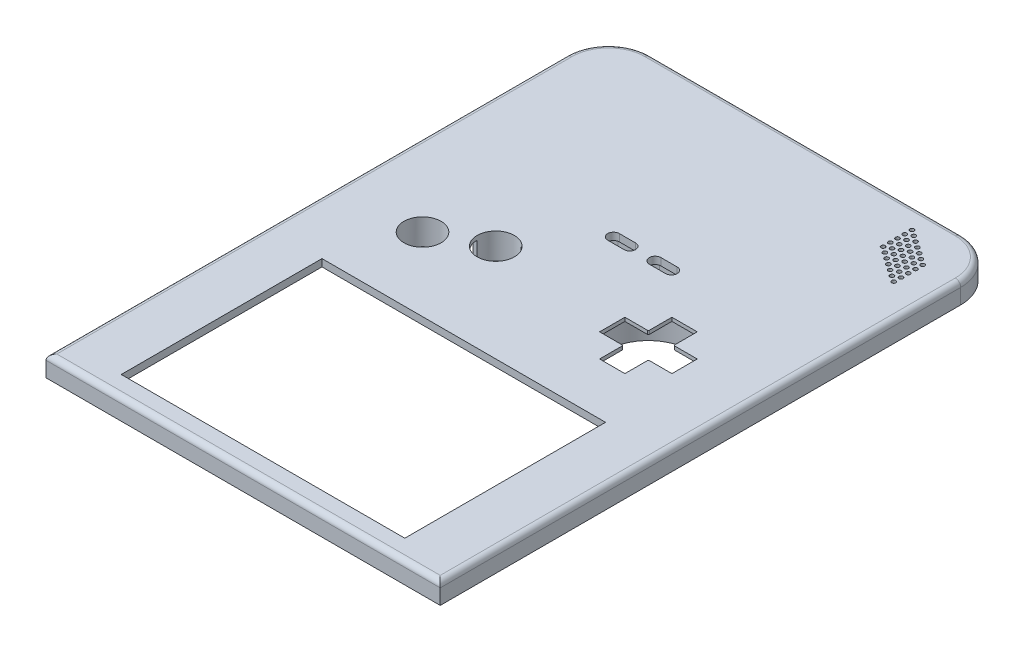
from build123d import *

# Parameters (mm, degrees)
SKETCH1_W            = 109
SKETCH1_H            = 155.5
BOSS_EXTRUDE1_DEPTH  = 5.7
SKETCH2_W            = 104.9
SKETCH2_H            = 151.4
CUT_EXTRUDE1_DEPTH   = 3.7
CUT_EXTRUDE3_DEPTH   = 6.7
SKETCH15_R           = 12.3
SKETCH15_R_2         = 11.3
BOSS_EXTRUDE27_DEPTH = 3.15
SKETCH4_W            = 78.4
SKETCH4_H            = 55.5
CUT_EXTRUDE4_DEPTH   = 6.7
SKETCH5_R            = 3.85
BOSS_EXTRUDE3_DEPTH  = 3.05
SKETCH8_R            = 12.85
SKETCH8_R_2          = 11.75
SKETCH8_R_3          = 6.25
SKETCH8_R_4          = 5.15
BOSS_EXTRUDE5_DEPTH  = 5.15
SKETCH9_R            = 1
BOSS_EXTRUDE6_DEPTH  = 5.6
CUT_EXTRUDE7_REACH   = 4
SKETCH12_R           = 11.75
CUT_EXTRUDE8_DEPTH   = 1
CUT_EXTRUDE9_REACH   = 4
SKETCH13_R           = 5.15
BOSS_EXTRUDE10_DEPTH = 5.7
SKETCH16_R           = 0.562045066
CUT_EXTRUDE13_DEPTH  = 2
FILLET3_R            = 0.25
CUT_EXTRUDE24_DEPTH  = 6
SKETCH19_R           = 1
BOSS_EXTRUDE28_DEPTH = 5.6
CHAMFER1_SIZE        = 0.25
CUT_EXTRUDE18_DEPTH  = 8.6
BOSS_EXTRUDE29_START = -5.7
BOSS_EXTRUDE29_DEPTH = 3.7
FILLET2_R            = 1.5
BOSS_EXTRUDE30_DEPTH = 3.15
CUT_EXTRUDE26_DEPTH  = 8.15


with BuildPart() as part:
    # Sketch1 → Boss-Extrude1 (new body)
    with BuildSketch(Plane(origin=(0, 0, 0), x_dir=(1, 0, 0), z_dir=(0, 1, 0))):
        Rectangle(SKETCH1_W, SKETCH1_H)
    extrude(amount=BOSS_EXTRUDE1_DEPTH)

    # Sketch2 → Cut-Extrude1 (cut)
    with BuildSketch(Plane(origin=(0, 0, 0), x_dir=(-1, 0, 0), z_dir=(0, -1, 0))):
        Rectangle(SKETCH2_W, SKETCH2_H)
    extrude(amount=-CUT_EXTRUDE1_DEPTH, mode=Mode.SUBTRACT)

    # Sketch3 → Cut-Extrude3 (cut, through all)
    with BuildSketch(Plane(origin=(0, 5.7, 0), x_dir=(1, 0, 0), z_dir=(0, 1, 0))):
        with BuildLine():
            ThreePointArc((42.9, 77.75), (51.102438662, 74.352438662), (54.5, 66.15))
            Line((54.5, 66.15), (54.5, 77.75))
            Line((54.5, 77.75), (42.9, 77.75))
        make_face()
    extrude(amount=-CUT_EXTRUDE3_DEPTH, mode=Mode.SUBTRACT)

    # Sketch15 → Boss-Extrude27 (add)
    with BuildSketch(Plane.XZ.offset(-3.7)):
        with Locations((41.14, -64.39)):
            Circle(SKETCH15_R)
        with Locations((41.14, -64.39)):
            Circle(SKETCH15_R_2, mode=Mode.SUBTRACT)
    extrude(amount=BOSS_EXTRUDE27_DEPTH)

    # Sketch4 → Cut-Extrude4 (cut, through all)
    with BuildSketch(Plane(origin=(0, 5.7, 0), x_dir=(1, 0, 0), z_dir=(0, 1, 0))):
        with Locations((0, -44.5)):
            Rectangle(SKETCH4_W, SKETCH4_H)
    extrude(amount=-CUT_EXTRUDE4_DEPTH, mode=Mode.SUBTRACT)

    # Sketch5 → Boss-Extrude3 (add)
    with BuildSketch(Plane.XZ.offset(-3.7)):
        with Locations((46.05, 68.22282905)):
            Circle(SKETCH5_R)
        Polygon((49.177494429, 69.423361681), (46.574055458, 71.531584991), (43.446561029, 70.33105236), (42.922505571, 67.022296419), (45.525944542, 64.914073109), (48.653438971, 66.11460574), align=None, mode=Mode.SUBTRACT)
        with Locations((-46.05, 68.22282905)):
            Circle(SKETCH5_R)
        Polygon((-48.653438971, 66.11460574), (-49.177494429, 69.423361681), (-46.574055458, 71.531584991), (-43.446561029, 70.33105236), (-42.922505571, 67.022296419), (-45.525944542, 64.914073109), align=None, mode=Mode.SUBTRACT)
        with Locations((-46.05, -68.22282905)):
            Circle(SKETCH5_R)
        Polygon((-49.177494429, -69.423361681), (-46.574055458, -71.531584991), (-43.446561029, -70.33105236), (-42.922505571, -67.022296419), (-45.525944542, -64.914073109), (-48.653438971, -66.11460574), align=None, mode=Mode.SUBTRACT)
    extrude(amount=BOSS_EXTRUDE3_DEPTH)

    # Sketch8 → Boss-Extrude5 (add)
    with BuildSketch(Plane.XZ.offset(-3.7)):
        with Locations((26.715, -7.585)):
            Circle(SKETCH8_R)
        with Locations((26.715, -7.585)):
            Circle(SKETCH8_R_2, mode=Mode.SUBTRACT)
        with Locations((-31.65, -3.5)):
            Circle(SKETCH8_R_3)
        with Locations((-31.65, -3.5)):
            Circle(SKETCH8_R_4, mode=Mode.SUBTRACT)
        with Locations((-18.15, -10.25)):
            Circle(SKETCH8_R_3)
        with Locations((-18.15, -10.25)):
            Circle(SKETCH8_R_4, mode=Mode.SUBTRACT)
        with BuildLine():
            Line((0.4, -29.75), (-4.1, -29.75))
            ThreePointArc((-4.1, -29.75), (-5.1, -28.75), (-4.1, -27.75))
            Line((-4.1, -27.75), (0.4, -27.75))
            ThreePointArc((0.4, -27.75), (1.4, -28.75), (0.4, -29.75))
        make_face()
        with BuildLine():
            Line((11.9, -29.75), (7.4, -29.75))
            ThreePointArc((7.4, -29.75), (6.4, -28.75), (7.4, -27.75))
            Line((7.4, -27.75), (11.9, -27.75))
            ThreePointArc((11.9, -27.75), (12.9, -28.75), (11.9, -29.75))
        make_face()
    extrude(amount=BOSS_EXTRUDE5_DEPTH)

    # Sketch9 → Boss-Extrude6 (add)
    with BuildSketch(Plane.XZ.offset(-3.7)):
        with Locations((16.108398282, 3.021601718)):
            Circle(SKETCH9_R)
        with Locations((37.321601718, -18.191601718)):
            Circle(SKETCH9_R)
    extrude(amount=BOSS_EXTRUDE6_DEPTH)

    # Sketch11 → Cut-Extrude7 (cut, up to next)
    with BuildSketch(Plane.XZ.offset(-3.7), mode=Mode.PRIVATE) as cut_extrude7_sk1:
        Polygon((30.215, -4.085), (30.215, 2.415), (23.215, 2.415), (23.215, -4.085), (16.715, -4.085), (16.715, -11.085), (23.215, -11.085), (23.215, -17.585), (30.215, -17.585), (30.215, -11.085), (36.715, -11.085), (36.715, -4.085), align=None)
    cut_extrude7_tool1 = extrude(cut_extrude7_sk1.sketch, amount=-CUT_EXTRUDE7_REACH, mode=Mode.PRIVATE) & part.part
    add(cut_extrude7_tool1.solids().sort_by_distance((26.715, 3.7, -7.585))[0], mode=Mode.SUBTRACT)

    # Sketch12 → Cut-Extrude8 (cut)
    with BuildSketch(Plane.XZ.offset(-3.7)):
        with Locations((26.715, -7.585)):
            Circle(SKETCH12_R)
    extrude(amount=-CUT_EXTRUDE8_DEPTH, mode=Mode.SUBTRACT)

    # Sketch13 → Cut-Extrude9 (cut, up to next)
    with BuildSketch(Plane(origin=(0, 3.7, 0), x_dir=(-1, 0, 0), z_dir=(0, -1, 0)), mode=Mode.PRIVATE) as cut_extrude9_sk1:
        with Locations((31.65, 3.5)):
            Circle(SKETCH13_R)
    cut_extrude9_tool1 = extrude(cut_extrude9_sk1.sketch, amount=-CUT_EXTRUDE9_REACH, mode=Mode.PRIVATE) & part.part
    add(cut_extrude9_tool1.solids().sort_by_distance((-31.65, 3.7, -3.5))[0], mode=Mode.SUBTRACT)
    # Sketch13 → Cut-Extrude9 (cut, up to next)
    with BuildSketch(Plane(origin=(0, 3.7, 0), x_dir=(-1, 0, 0), z_dir=(0, -1, 0)), mode=Mode.PRIVATE) as cut_extrude9_sk2:
        with Locations((18.15, 10.25)):
            Circle(SKETCH13_R)
    cut_extrude9_tool2 = extrude(cut_extrude9_sk2.sketch, amount=-CUT_EXTRUDE9_REACH, mode=Mode.PRIVATE) & part.part
    add(cut_extrude9_tool2.solids().sort_by_distance((-18.15, 3.7, -10.25))[0], mode=Mode.SUBTRACT)

    # Sketch3_9 → Boss-Extrude10 (add)
    with BuildSketch(Plane(origin=(0, 5.7, 0), x_dir=(1, 0, 0), z_dir=(0, 1, 0))):
        with BuildLine():
            ThreePointArc((42.9, 75.7), (49.65286976, 72.90286976), (52.45, 66.15))
            Line((52.45, 66.15), (54.5, 66.15))
            ThreePointArc((54.5, 66.15), (51.102438662, 74.352438662), (42.9, 77.75))
            Line((42.9, 77.75), (42.9, 75.7))
        make_face()
    extrude(amount=-BOSS_EXTRUDE10_DEPTH)

    # Sketch16 → Cut-Extrude13 (cut)
    with BuildSketch(Plane(origin=(0, 3.7, 0), x_dir=(-1, 0, 0), z_dir=(0, -1, 0))):
        with Locations((-35.52735827, 63.649490355)):
            Circle(SKETCH16_R)
        with Locations((-37.165662359, 62.502337482)):
            Circle(SKETCH16_R)
        with Locations((-38.803966447, 61.35518461)):
            Circle(SKETCH16_R)
        with Locations((-40.442270536, 60.208031737)):
            Circle(SKETCH16_R)
        with Locations((-42.080574624, 59.060878864)):
            Circle(SKETCH16_R)
        with Locations((-43.718878713, 57.913725991)):
            Circle(SKETCH16_R)
        with Locations((-45.357182802, 56.766573119)):
            Circle(SKETCH16_R)
        with Locations((-37.165662359, 64.502337482)):
            Circle(SKETCH16_R)
        with Locations((-38.803966447, 63.35518461)):
            Circle(SKETCH16_R)
        with Locations((-40.442270536, 62.208031737)):
            Circle(SKETCH16_R)
        with Locations((-42.080574624, 61.060878864)):
            Circle(SKETCH16_R)
        with Locations((-43.718878713, 59.913725991)):
            Circle(SKETCH16_R)
        with Locations((-45.357182802, 58.766573119)):
            Circle(SKETCH16_R)
        with Locations((-37.165662359, 66.502337482)):
            Circle(SKETCH16_R)
        with Locations((-38.803966447, 65.35518461)):
            Circle(SKETCH16_R)
        with Locations((-40.442270536, 64.208031737)):
            Circle(SKETCH16_R)
        with Locations((-42.080574624, 63.060878864)):
            Circle(SKETCH16_R)
        with Locations((-43.718878713, 61.913725991)):
            Circle(SKETCH16_R)
        with Locations((-45.357182802, 60.766573119)):
            Circle(SKETCH16_R)
        with Locations((-37.165662359, 68.502337482)):
            Circle(SKETCH16_R)
        with Locations((-38.803966447, 67.35518461)):
            Circle(SKETCH16_R)
        with Locations((-40.442270536, 66.208031737)):
            Circle(SKETCH16_R)
        with Locations((-42.080574624, 65.060878864)):
            Circle(SKETCH16_R)
        with Locations((-43.718878713, 63.913725991)):
            Circle(SKETCH16_R)
        with Locations((-45.357182802, 62.766573119)):
            Circle(SKETCH16_R)
        with Locations((-37.165662359, 70.502337482)):
            Circle(SKETCH16_R)
        with Locations((-38.803966447, 69.35518461)):
            Circle(SKETCH16_R)
        with Locations((-40.442270536, 68.208031737)):
            Circle(SKETCH16_R)
        with Locations((-42.080574624, 67.060878864)):
            Circle(SKETCH16_R)
        with Locations((-43.718878713, 65.913725991)):
            Circle(SKETCH16_R)
        with Locations((-45.357182802, 64.766573119)):
            Circle(SKETCH16_R)
        with Locations((-35.52735827, 65.649490355)):
            Circle(SKETCH16_R)
        with Locations((-35.52735827, 67.649490355)):
            Circle(SKETCH16_R)
        with Locations((-35.52735827, 69.649490355)):
            Circle(SKETCH16_R)
        with Locations((-35.52735827, 71.649490355)):
            Circle(SKETCH16_R)
    extrude(amount=-CUT_EXTRUDE13_DEPTH, mode=Mode.SUBTRACT)

    # Fillet3
    fillet3_edges = [part.edges().sort_by_distance(p)[0] for p in [
        (30.215, 5.2, -11.085),
        (23.215, 5.2, -11.085),
        (23.215, 5.2, -4.085),
        (30.215, 5.2, -4.085),
    ]]
    fillet(fillet3_edges, radius=FILLET3_R)

    # Sketch18 → Cut-Extrude24 (cut)
    with BuildSketch(Plane.XZ.offset(1.45)):
        Polygon((-16.137205771, -6.051171399), (-14.510860175, -7.677516996), (-10.832101403, -4.558447), (-12.458447, -2.932101403), align=None)
        with BuildLine():
            Line((-18.15, -10.25), (-21.536530628, -3.165016871))
            ThreePointArc((-21.536530628, -3.165016871), (-24.793008767, -6.062398043), (-26.002743191, -10.25))
            Line((-26.002743191, -10.25), (-18.15, -10.25))
        make_face()
        Polygon((-12.458447, -17.567898597), (-10.832101403, -15.941553), (-14.510860175, -12.822483004), (-16.137205771, -14.448828601), align=None)
    extrude(amount=-CUT_EXTRUDE24_DEPTH, mode=Mode.SUBTRACT)

    # Sketch19 → Boss-Extrude28 (add)
    with BuildSketch(Plane.XZ.offset(-3.7)):
        with Locations((-30.260814579, -11.378462024)):
            Circle(SKETCH19_R)
    extrude(amount=BOSS_EXTRUDE28_DEPTH)

    # Chamfer1
    chamfer1_edges = [part.edges().sort_by_distance(p)[0] for p in [
        (15.108398282, -1.9, 3.021601718),
        (36.321601718, -1.9, -18.191601718),
        (-31.260814579, -1.9, -11.378462024),
    ]]
    chamfer(chamfer1_edges, length=CHAMFER1_SIZE)

    # Sketch3_12 → Cut-Extrude18 (cut, through all)
    with BuildSketch(Plane(origin=(0, 5.7, 0), x_dir=(1, 0, 0), z_dir=(0, 1, 0))):
        with BuildLine():
            ThreePointArc((-54.5, 66.15), (-51.102438662, 74.352438662), (-42.9, 77.75))
            Line((-42.9, 77.75), (-54.5, 77.75))
            Line((-54.5, 77.75), (-54.5, 66.15))
        make_face()
    extrude(amount=-CUT_EXTRUDE18_DEPTH, mode=Mode.SUBTRACT)

    # Sketch3_14 → Boss-Extrude29 (add)
    with BuildSketch(Plane(origin=(0, 5.7, 0), x_dir=(1, 0, 0), z_dir=(0, 1, 0)).offset(BOSS_EXTRUDE29_START)):
        with BuildLine():
            Line((-42.9, 75.7), (-42.9, 77.75))
            ThreePointArc((-42.9, 77.75), (-51.102438662, 74.352438662), (-54.5, 66.15))
            Line((-54.5, 66.15), (-52.45, 66.15))
            ThreePointArc((-52.45, 66.15), (-49.65286976, 72.90286976), (-42.9, 75.7))
        make_face()
    extrude(amount=BOSS_EXTRUDE29_DEPTH)

    # Fillet2
    fillet2_edges = [part.edges().sort_by_distance(p)[0] for p in [
        (0, 5.7, 77.75),
        (0, 5.7, -77.75),
        (51.102438662, 5.7, -74.352438662),
        (54.5, 5.7, 5.8),
        (-54.5, 5.7, 5.8),
        (-51.102438662, 5.7, -74.352438662),
    ]]
    fillet(fillet2_edges, radius=FILLET2_R)

    # Sketch22 → Boss-Extrude30 (add)
    with BuildSketch(Plane.XZ.offset(-3.7)):
        with BuildLine():
            Line((12.814788301, -32), (-5.185211699, -32))
            ThreePointArc((-5.185211699, -32), (-8.185211699, -29), (-5.185211699, -26))
            Line((-5.185211699, -26), (12.814788301, -26))
            ThreePointArc((12.814788301, -26), (15.814788301, -29), (12.814788301, -32))
        make_face()
        with BuildLine():
            Line((6.4, -27), (12.9, -27))
            ThreePointArc((12.9, -27), (14.9, -29), (12.9, -31))
            Line((12.9, -31), (6.4, -31))
            ThreePointArc((6.4, -31), (4.4, -29), (6.4, -27))
        make_face(mode=Mode.SUBTRACT)
        with BuildLine():
            Line((-5.1, -27), (1.4, -27))
            ThreePointArc((1.4, -27), (3.4, -29), (1.4, -31))
            Line((1.4, -31), (-5.1, -31))
            ThreePointArc((-5.1, -31), (-7.1, -29), (-5.1, -27))
        make_face(mode=Mode.SUBTRACT)
    extrude(amount=BOSS_EXTRUDE30_DEPTH)

    # Sketch23 → Cut-Extrude26 (cut, through all)
    with BuildSketch(Plane.XZ.offset(1.45)):
        with BuildLine():
            Line((-4.1, -27.15), (0.4, -27.15))
            ThreePointArc((0.4, -27.15), (2, -28.75), (0.4, -30.35))
            Line((0.4, -30.35), (-4.1, -30.35))
            ThreePointArc((-4.1, -30.35), (-5.7, -28.75), (-4.1, -27.15))
        make_face()
        with BuildLine():
            Line((7.4, -27.15), (11.9, -27.15))
            ThreePointArc((11.9, -27.15), (13.5, -28.75), (11.9, -30.35))
            Line((11.9, -30.35), (7.4, -30.35))
            ThreePointArc((7.4, -30.35), (5.8, -28.75), (7.4, -27.15))
        make_face()
    extrude(amount=-CUT_EXTRUDE26_DEPTH, mode=Mode.SUBTRACT)


solid = part.part
